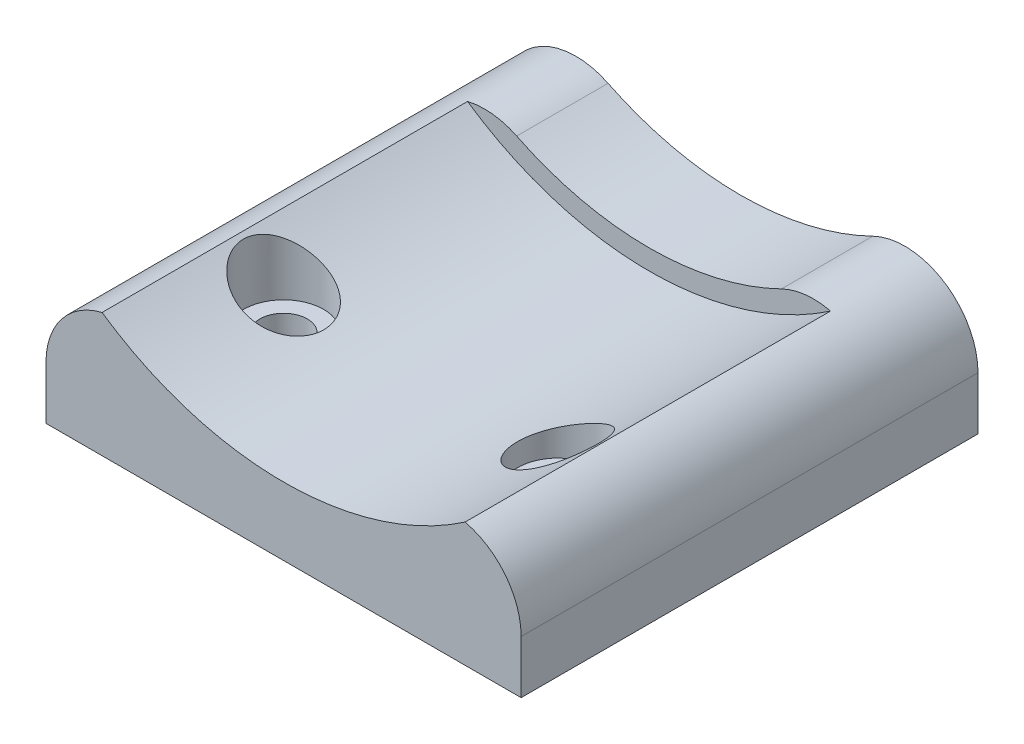
from build123d import *

# Parameters (mm, degrees)
BOSS_EXTRUDE1_DEPTH = 63.5
SKETCH7_R           = 44.704
CUT_EXTRUDE1_DEPTH  = 50.8
SKETCH8_R           = 3.302
CUT_EXTRUDE2_DEPTH  = 18.526
SKETCH9_R           = 5.588
CUT_EXTRUDE3_DEPTH  = 10.144


with BuildPart() as part:
    # Sketch2 → Boss-Extrude1 (new body)
    with BuildSketch(Plane.XY):
        with BuildLine():
            Line((-33.02, 0), (-33.02, 7.366))
            ThreePointArc((-33.02, 7.366), (-28.240847698, 15.984124973), (-18.399512195, 16.494507465))
            ThreePointArc((-18.399512195, 16.494507465), (0, 12.239600759), (18.399512195, 16.494507465))
            ThreePointArc((18.399512195, 16.494507465), (28.240847698, 15.984124973), (33.02, 7.366))
            Line((33.02, 7.366), (33.02, 0))
            Line((33.02, 0), (-33.02, 0))
        make_face()
    extrude(amount=-BOSS_EXTRUDE1_DEPTH)

    # Sketch7 → Cut-Extrude1 (cut)
    with BuildSketch(Plane.XY):
        with Locations((0, 54.149600759)):
            Circle(SKETCH7_R)
    extrude(amount=-CUT_EXTRUDE1_DEPTH, mode=Mode.SUBTRACT)

    # Sketch8 → Cut-Extrude2 (cut, through all)
    with BuildSketch(Plane(origin=(0, 0, 0), x_dir=(-1, 0, 0), z_dir=(0, -1, 0))):
        with Locations((19.05, 19.05)):
            Circle(SKETCH8_R)
        with Locations((-19.05, 19.05)):
            Circle(SKETCH8_R)
    extrude(amount=-CUT_EXTRUDE2_DEPTH, mode=Mode.SUBTRACT)

    # Sketch9 → Cut-Extrude3 (cut, through all)
    with BuildSketch(Plane(origin=(0, 8.382, 0), x_dir=(-1, 0, 0), z_dir=(0, -1, 0))):
        with Locations((19.05, 19.05)):
            Circle(SKETCH9_R)
        with Locations((-19.05, 19.05)):
            Circle(SKETCH9_R)
    extrude(amount=-CUT_EXTRUDE3_DEPTH, mode=Mode.SUBTRACT)


solid = part.part
